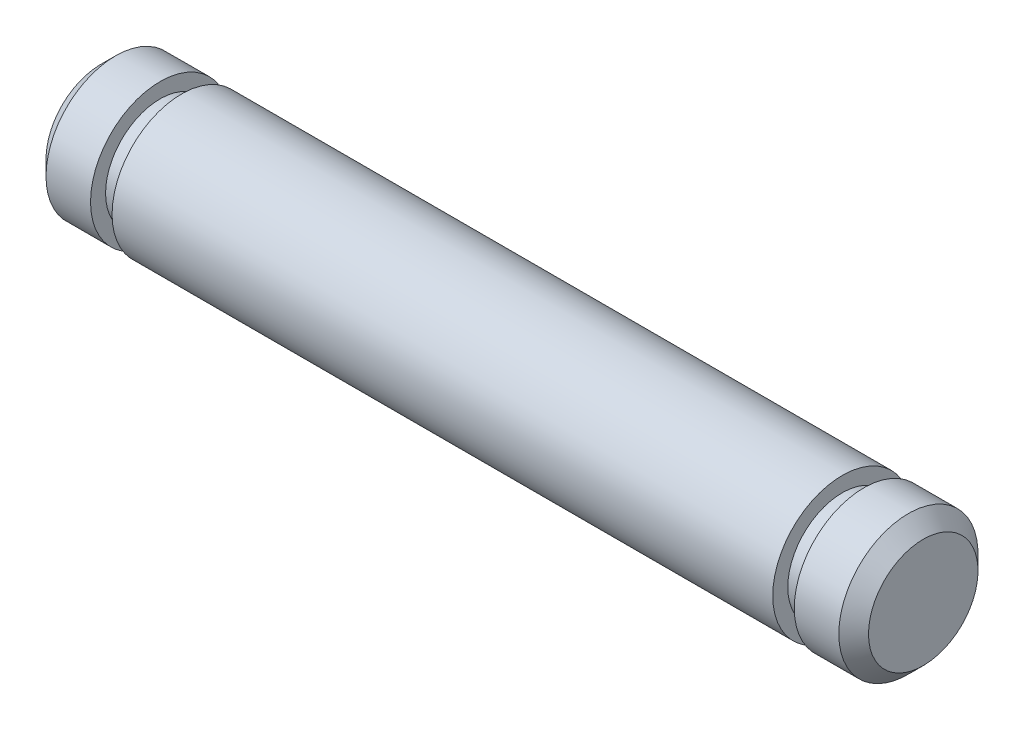
from build123d import *

# Parameters (mm, degrees)
CHAMFER1_SIZE = 0.508


with BuildPart() as part:
    # Sketch1 → Revolve1 (revolve)
    with BuildSketch(Plane.XY):
        Polygon((-7.5946, 0), (20.5486, 0), (20.5486, 2.38125), (18.5166, 2.38125), (18.5166, 1.8669), (17.78, 1.8669), (17.78, 2.38125), (-4.826, 2.38125), (-4.826, 1.8669), (-5.5626, 1.8669), (-5.5626, 2.38125), (-7.5946, 2.38125), align=None)
    revolve(axis=Axis((20.5486, 0, 0), (1, 0, 0)))

    # Chamfer1
    chamfer1_edges = [part.edges().sort_by_distance(p)[0] for p in [
        (-7.5946, -2.38125, 0),
        (20.5486, -2.38125, 0),
    ]]
    chamfer(chamfer1_edges, length=CHAMFER1_SIZE)


solid = part.part
